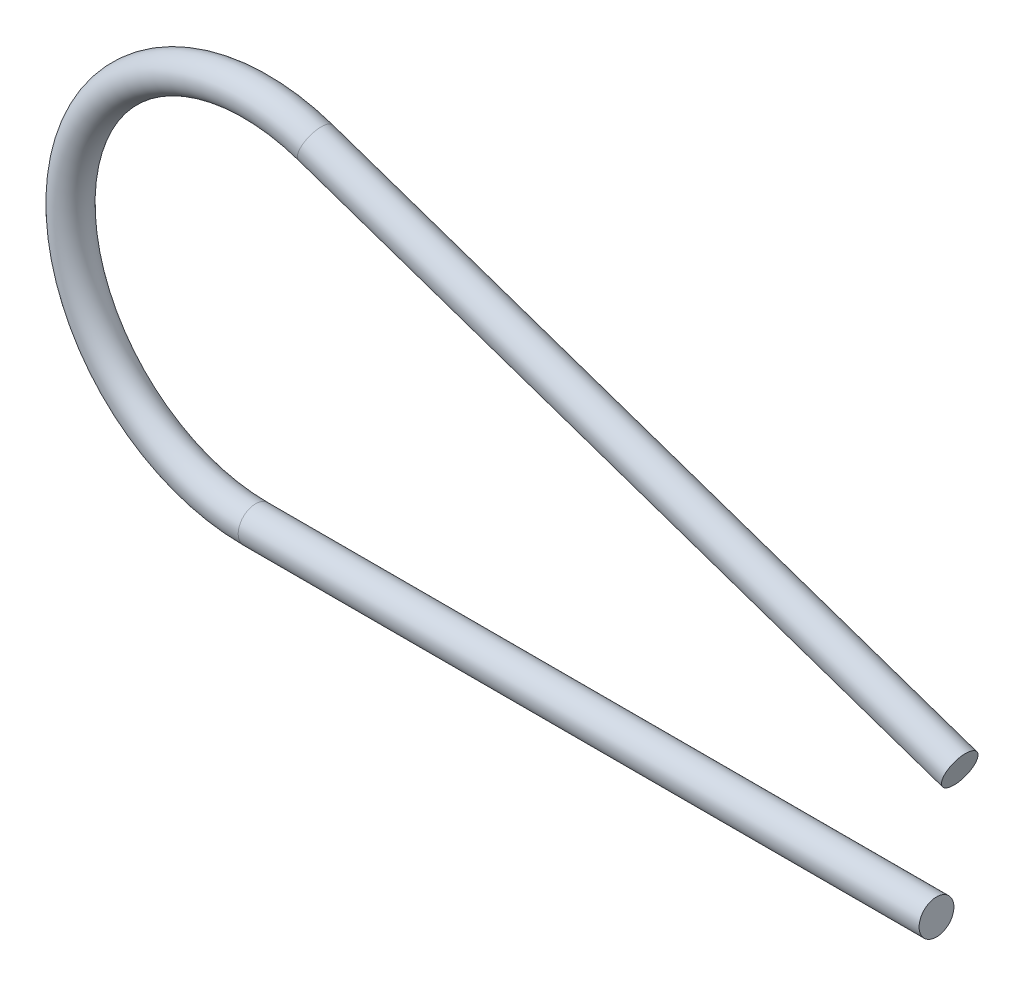
from build123d import *

# Parameters (mm, degrees)
SKETCH2_R = 0.15


with BuildPart() as part:
    # Sweep1: sweep along a curve in space
    with BuildLine() as sweep1_path:
        Line((0.200364375, 1.203010725, 0), (-5.352761358, 3.105560223, 0))
        ThreePointArc((-5.352761358, 3.105560223, 0), (-7.444169631, 1.858035589, 0), (-5.87, 0, 0))
        Line((-5.87, 0, 0), (0, 0, 0))
    # Sketch2 → Sweep1 (sweep)
    with BuildSketch(Plane(origin=(0, 0, 0), x_dir=(0, 0, -1), z_dir=(1, 0, 0))):
        Circle(SKETCH2_R)
    sweep(path=sweep1_path.line)


solid = part.part
